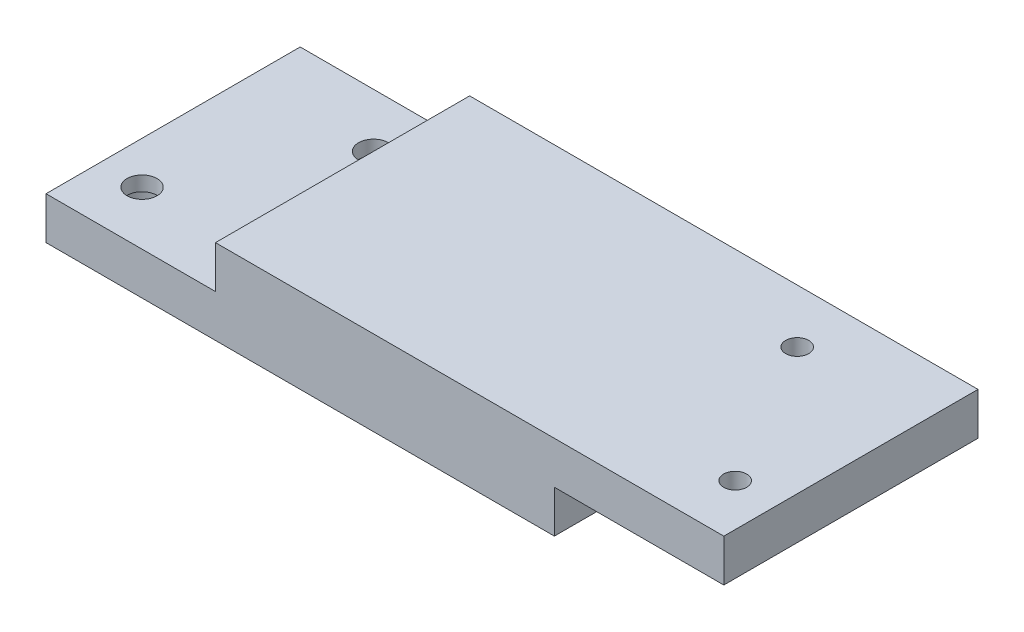
from build123d import *

# Parameters (mm, degrees)
SKETCH1_W                                      = 25.4
SKETCH1_H                                      = 38.1
SKETCH1_W_2                                    = 50.8
BOSS_EXTRUDE1_DEPTH                            = 6.35
SKETCH1_3_W                                    = 50.8
SKETCH1_3_H                                    = 38.1
SKETCH1_3_W_2                                  = 25.4
BOSS_EXTRUDE2_DEPTH                            = 6.35
CBORE_FOR_8_SOCKET_HEAD_CAP_SCREW1_D           = 4.4958
CBORE_FOR_8_SOCKET_HEAD_CAP_SCREW1_DEPTH       = 6.35
CBORE_FOR_8_SOCKET_HEAD_CAP_SCREW1_CBORE_D     = 7.9375
CBORE_FOR_8_SOCKET_HEAD_CAP_SCREW1_CBORE_DEPTH = 4.1656
F_8_32_TAPPED_HOLE1_D                          = 3.4544


with BuildPart() as part:
    # Sketch1 → Boss-Extrude1 (new body)
    with BuildSketch(Plane(origin=(0, 0, 0), x_dir=(1, 0, 0), z_dir=(0, 1, 0))):
        with Locations((-38.1, 0)):
            Rectangle(SKETCH1_W, SKETCH1_H)
        Rectangle(SKETCH1_W_2, SKETCH1_H)
    extrude(amount=-BOSS_EXTRUDE1_DEPTH)

    # Sketch1_3 → Boss-Extrude2 (add)
    with BuildSketch(Plane(origin=(0, 0, 0), x_dir=(1, 0, 0), z_dir=(0, 1, 0))):
        Rectangle(SKETCH1_3_W, SKETCH1_3_H)
        with Locations((38.1, 0)):
            Rectangle(SKETCH1_3_W_2, SKETCH1_3_H)
    extrude(amount=BOSS_EXTRUDE2_DEPTH)

    # CBORE for _8 Socket Head Cap Screw1
    with Locations(Plane(origin=(0, -6.35, 0), x_dir=(-1, 0, 0), z_dir=(0, -1, 0))):
        with Locations((31.75, 10.998522628), (44.45, -10.998522628)):
            CounterBoreHole(CBORE_FOR_8_SOCKET_HEAD_CAP_SCREW1_D / 2, CBORE_FOR_8_SOCKET_HEAD_CAP_SCREW1_CBORE_D / 2, CBORE_FOR_8_SOCKET_HEAD_CAP_SCREW1_CBORE_DEPTH, depth=CBORE_FOR_8_SOCKET_HEAD_CAP_SCREW1_DEPTH)

    # 8-32 Tapped Hole1 (through all)
    with Locations(Plane(origin=(0, 0, 0), x_dir=(-1, 0, 0), z_dir=(0, -1, 0))):
        with Locations((-31.75, 10.998522628), (-44.45, -10.998522628)):
            Hole(F_8_32_TAPPED_HOLE1_D / 2)


solid = part.part
